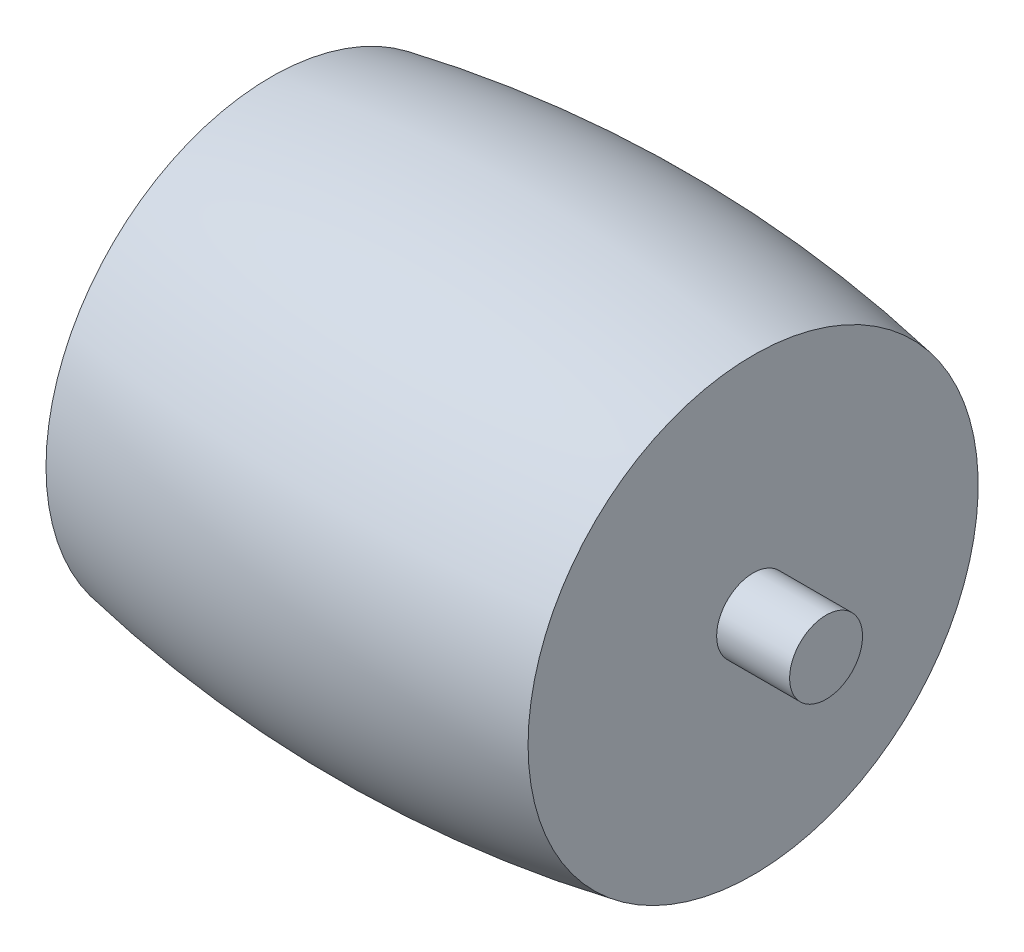
from build123d import *

# Parameters (mm, degrees)
SCALE1_SCALE = 0.630434783


with BuildPart() as part:
    # Sketch1 → Revolve1 (revolve)
    with BuildSketch(Plane.XY):
        with BuildLine():
            Line((9.25, 49.136926033), (9.25, 41.9))
            Line((9.25, 41.9), (12.05, 41.9))
            Line((12.05, 41.9), (12.05, 40.5))
            Line((12.05, 40.5), (9.25, 40.5))
            Line((9.25, 40.5), (-9.25, 40.5))
            Line((-9.25, 40.5), (-12.05, 40.5))
            Line((-12.05, 40.5), (-12.05, 41.9))
            Line((-12.05, 41.9), (-9.25, 41.9))
            Line((-9.25, 41.9), (-9.25, 49.136926033))
            ThreePointArc((-9.25, 49.136926033), (0, 50), (9.25, 49.136926033))
        make_face()
    revolve(axis=Axis((-9.25, 40.5, 0), (1, 0, 0)))


with BuildPart() as part_1:
    # Scale1: scaled about (0, 0, 0)
    add(part.part.scale(SCALE1_SCALE))


solid = part_1.part
